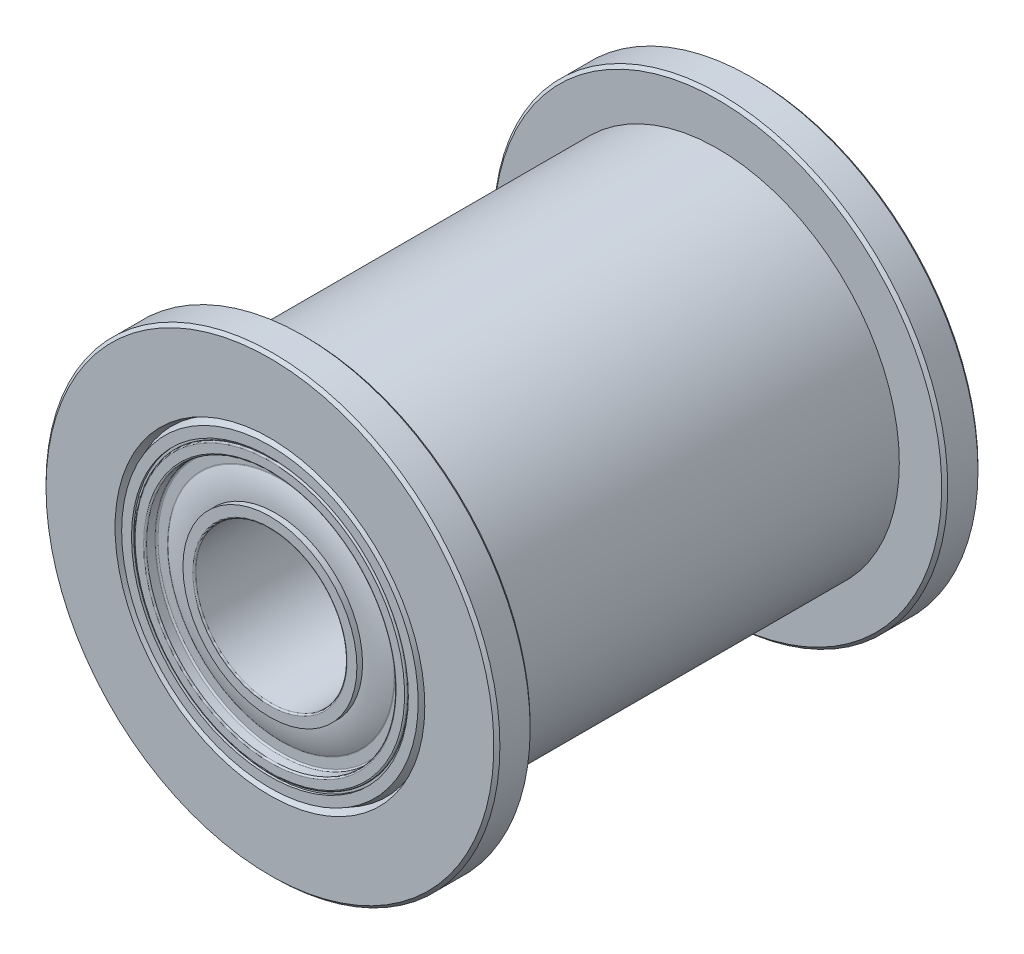
from build123d import *

# Parameters (mm, degrees)
CHAMFER1_SIZE = 0.1
FILLET2_R     = 0.05


with BuildPart() as part:
    # Sketch2 → Revolve1 (revolve)
    with BuildSketch(Plane(origin=(0, 0, 0), x_dir=(0, 0, -1), z_dir=(1, 0, 0))):
        with BuildLine():
            Line((8, 2.5), (0, 2.5))
            Line((0, 2.5), (0, 4.5))
            Line((0, 4.5), (8, 4.5))
            Line((8, 4.5), (8, 4.125))
            Line((8, 4.125), (7.625, 4.125))
            Line((7.625, 4.125), (7.625, 3.75))
            ThreePointArc((7.625, 3.75), (7.765098905, 3.322431908), (7.8125, 2.875))
            Line((7.8125, 2.875), (8, 2.875))
            Line((8, 2.875), (8, 2.5))
        make_face()
    revolve(axis=Axis((0, 0, 8), (0, 0, -1)))

    # Mirror1: part across plane


with BuildPart() as part_1:
    add(part.part)
    add(part.part.mirror(Plane.XY))

    # Fillet2
    fillet2_edges = [part_1.edges().sort_by_distance(p)[0] for p in [
        (0, -2.5, -8),
        (0, -2.5, 8),
        (0, -4.5, 8),
        (0, -4.125, 8),
        (0, -4.125, 7.625),
        (0, -3.75, 7.625),
        (0, -2.875, -8),
        (0, -3.75, -7.625),
        (0, -4.125, -8),
        (0, -4.5, -8),
    ]]
    fillet(fillet2_edges, radius=FILLET2_R)


with BuildPart() as body_2:
    # Sketch3 → Revolve2 (revolve)
    with BuildSketch(Plane(origin=(0, 0, 0), x_dir=(0, 0, -1), z_dir=(1, 0, 0))):
        Polygon((6.8, 7.5), (8, 7.5), (8, 5.118382141), (7.7, 5.00919107), (8, 4.9), (8, 4.575), (7.925, 4.575), (7.925, 4.5), (-7.925, 4.5), (-7.925, 4.575), (-8, 4.575), (-8, 4.9), (-7.7, 5.00919107), (-8, 5.118382141), (-8, 7.5), (-6.8, 7.5), (-6.8, 6), (6.8, 6), align=None)
    revolve(axis=Axis((0, 0, 8), (0, 0, -1)))

    # Chamfer1
    chamfer1_edges = [body_2.edges().sort_by_distance(p)[0] for p in [
        (0, -7.5, 6.8),
        (0, -7.5, 8),
        (0, -7.5, -8),
        (0, -7.5, -6.8),
    ]]
    chamfer(chamfer1_edges, length=CHAMFER1_SIZE)

    # Combine1: union part
    add(part_1.part)


solid = body_2.part
